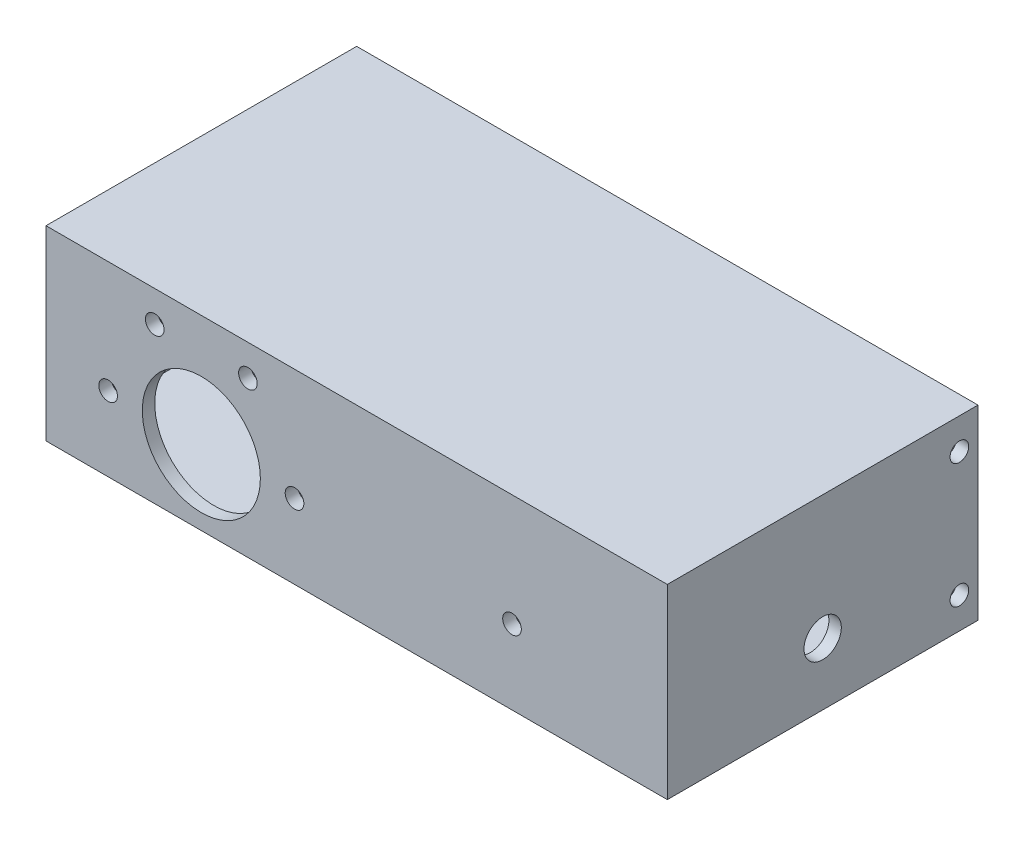
from build123d import *

# Parameters (mm, degrees)
SKETCH1_W           = 100
SKETCH1_H           = 30
SKETCH1_R           = 9.5
SKETCH1_R_2         = 1.5
BOSS_EXTRUDE1_DEPTH = 2
SKETCH2_W           = 100
SKETCH2_H           = 30
SKETCH2_W_2         = 96
SKETCH2_H_2         = 26
BOSS_EXTRUDE3_DEPTH = 50
CUT_EXTRUDE1_REACH  = 102
SKETCH4_R           = 5
SKETCH5_R           = 1.5
CUT_EXTRUDE2_DEPTH  = 101
SKETCH6_R           = 3
CUT_EXTRUDE3_DEPTH  = 101


with BuildPart() as part:
    # Sketch1 → Boss-Extrude1 (new body)
    with BuildSketch(Plane.XY):
        Rectangle(SKETCH1_W, SKETCH1_H)
        with Locations((-25, -3)):
            Circle(SKETCH1_R, mode=Mode.SUBTRACT)
        with Locations((-40, -3)):
            Circle(SKETCH1_R_2, mode=Mode.SUBTRACT)
        with Locations((-32.5, 9.990381057)):
            Circle(SKETCH1_R_2, mode=Mode.SUBTRACT)
        with Locations((-17.5, 9.990381057)):
            Circle(SKETCH1_R_2, mode=Mode.SUBTRACT)
        with Locations((-10, -3)):
            Circle(SKETCH1_R_2, mode=Mode.SUBTRACT)
        with Locations((25, -3)):
            Circle(SKETCH1_R_2, mode=Mode.SUBTRACT)
    extrude(amount=BOSS_EXTRUDE1_DEPTH)

    # Sketch2 → Boss-Extrude3 (add)
    with BuildSketch(Plane.XY.offset(2)):
        Rectangle(SKETCH2_W, SKETCH2_H)
        Rectangle(SKETCH2_W_2, SKETCH2_H_2, mode=Mode.SUBTRACT)
    extrude(amount=-BOSS_EXTRUDE3_DEPTH)

    # Sketch4 → Cut-Extrude1 (cut, up to next)
    with BuildSketch(Plane.ZY.offset(50), mode=Mode.PRIVATE) as cut_extrude1_sk1:
        with Locations((-38, 3)):
            Circle(SKETCH4_R)
    cut_extrude1_tool1 = extrude(cut_extrude1_sk1.sketch, amount=-CUT_EXTRUDE1_REACH, mode=Mode.PRIVATE) & part.part
    add(cut_extrude1_tool1.solids().sort_by_distance((-50, 3, -38))[0], mode=Mode.SUBTRACT)

    # Sketch5 → Cut-Extrude2 (cut, through all)
    with BuildSketch(Plane.ZY.offset(50)):
        with Locations((-45, 10)):
            Circle(SKETCH5_R)
        with Locations((-45, -10)):
            Circle(SKETCH5_R)
    extrude(amount=-CUT_EXTRUDE2_DEPTH, mode=Mode.SUBTRACT)

    # Sketch6 → Cut-Extrude3 (cut, through all)
    with BuildSketch(Plane.ZY.offset(50)):
        with Locations((-23, -5)):
            Circle(SKETCH6_R)
    extrude(amount=-CUT_EXTRUDE3_DEPTH, mode=Mode.SUBTRACT)


solid = part.part
